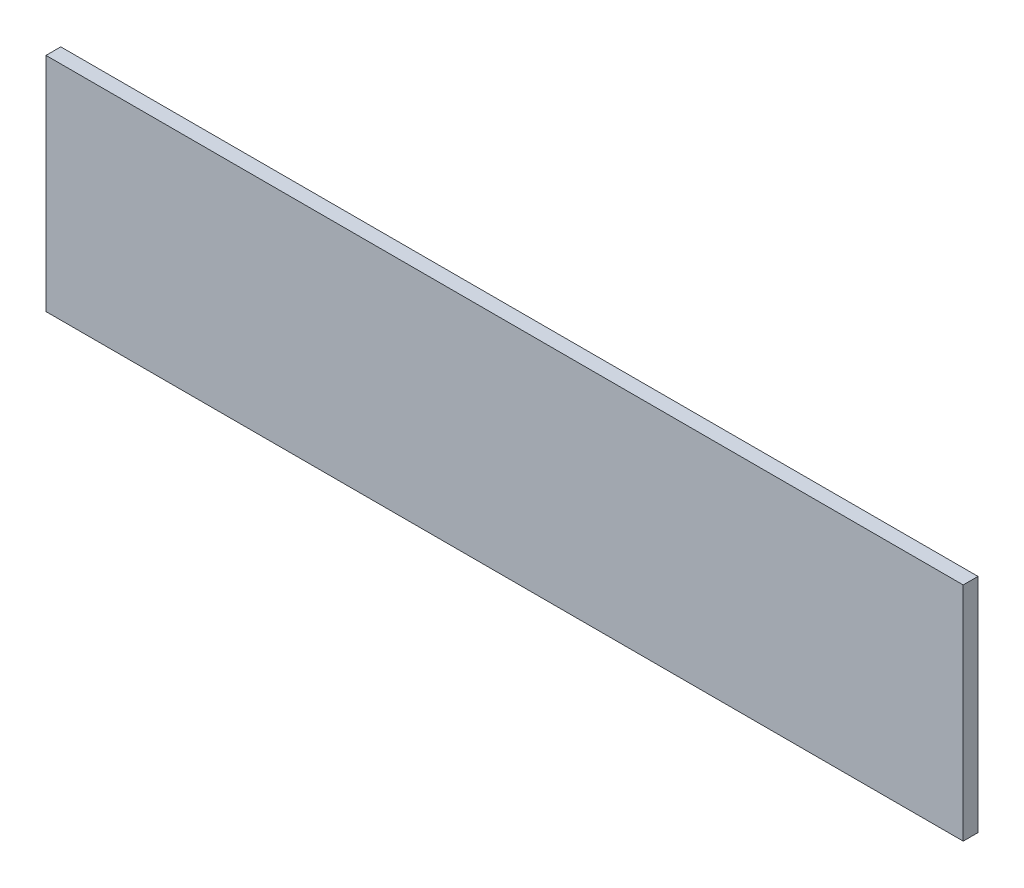
from build123d import *

# Parameters (mm, degrees)
SKETCH_1_W      = 124
SKETCH_1_H      = 30
EXTRUDE_1_DEPTH = 2


with BuildPart() as part:
    # 草图1 → 凸台-拉伸1 (new body)
    with BuildSketch(Plane.XY):
        Rectangle(SKETCH_1_W, SKETCH_1_H)
    extrude(amount=EXTRUDE_1_DEPTH)


solid = part.part
